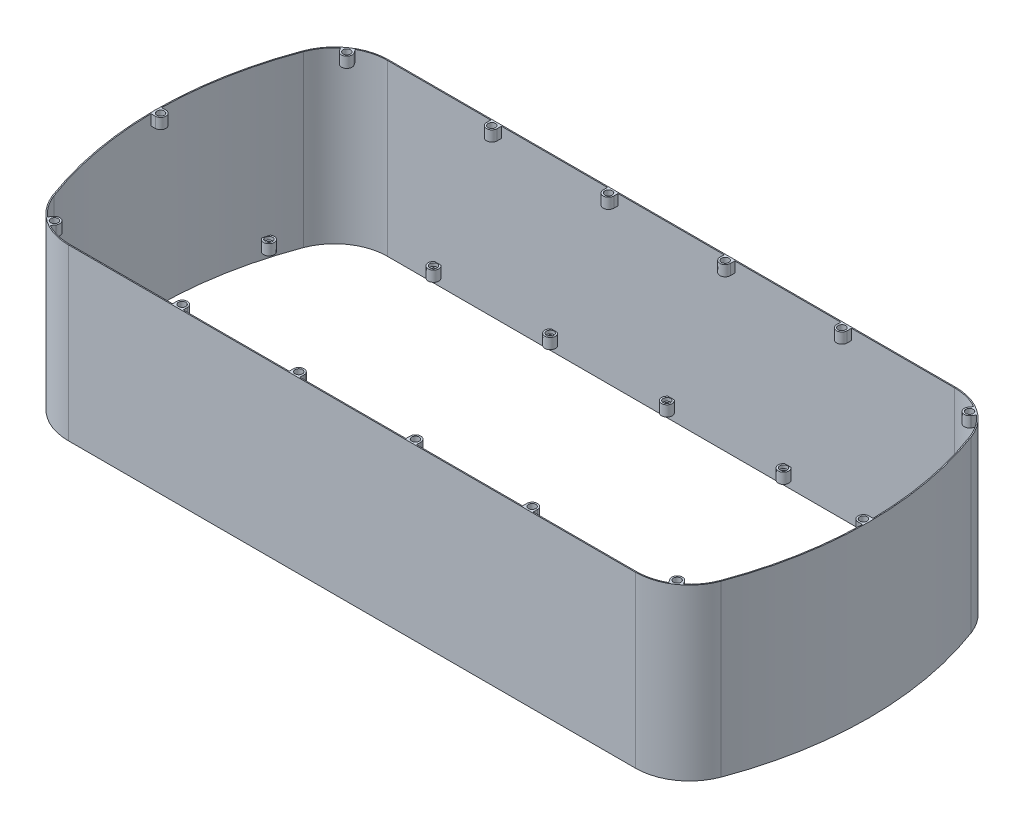
from build123d import *

# Parameters (mm, degrees)
SURFACE_EXTRUDE1_1_DEPTH                     = 160
THICKEN1_T1                                  = 1
BOSS_EXTRUDE1_START                          = -8
SKETCH2_R                                    = 3.4999999999999676
BOSS_EXTRUDE1_DEPTH                          = 10
BOSS_EXTRUDE2_START                          = -13
SKETCH2_3_R                                  = 3.4999999999999676
SKETCH2_3_R_2                                = 1.9999999999999967
BOSS_EXTRUDE2_DEPTH                          = 2
BOSS_EXTRUDE3_START                          = -8
SKETCH2_4_R                                  = 3.5000000000000737
BOSS_EXTRUDE3_DEPTH                          = 10
BOSS_EXTRUDE4_START                          = -13
SKETCH2_5_R                                  = 3.5000000000000737
SKETCH2_5_R_2                                = 2.000000000000103
BOSS_EXTRUDE4_DEPTH                          = 2
LPATTERN1_COUNT                              = 5
LPATTERN1_PITCH                              = 110
MIRROR1_START                                = -8
MIRROR1_AT_THE_SECOND_PLANE_COPY_1_SKETC_R   = 3.5000000000000737
MIRROR1_AT_THE_SECOND_PLANE_COPY_1_DEPTH     = 10
MIRROR1_START_2                              = -13
MIRROR1_AT_THE_SECOND_PLANE_COPY_2_SKETC_R   = 3.5000000000000737
MIRROR1_AT_THE_SECOND_PLANE_COPY_2_SKETC_R_2 = 2.000000000000103
MIRROR1_AT_THE_SECOND_PLANE_COPY_2_DEPTH     = 2
SKETCH3_R                                    = 3.4999999999999676
BOSS_EXTRUDE5_DEPTH                          = 10
BOSS_EXTRUDE6_START                          = -5
SKETCH3_3_R                                  = 3.4999999999999676
SKETCH3_3_R_2                                = 1.9999999999999967
BOSS_EXTRUDE6_DEPTH                          = 5
LPATTERN2_COUNT                              = 4
LPATTERN2_PITCH                              = 110
SKETCH3_5_R                                  = 3.500000000000021
BOSS_EXTRUDE7_DEPTH                          = 10
BOSS_EXTRUDE8_START                          = -5
SKETCH3_6_R                                  = 3.500000000000021
SKETCH3_6_R_2                                = 1.9999999999999967
BOSS_EXTRUDE8_DEPTH                          = 5
MIRROR2_AT_THE_SECOND_PLANE_COPY_1_SKETC_R   = 3.500000000000021
MIRROR2_AT_THE_SECOND_PLANE_COPY_1_DEPTH     = 10
MIRROR2_START                                = -5
MIRROR2_AT_THE_SECOND_PLANE_COPY_2_SKETC_R   = 3.500000000000021
MIRROR2_AT_THE_SECOND_PLANE_COPY_2_SKETC_R_2 = 1.9999999999999967
MIRROR2_AT_THE_SECOND_PLANE_COPY_2_DEPTH     = 5
SKETCH3_7_R                                  = 3.4999999999999623
BOSS_EXTRUDE9_DEPTH                          = 10
BOSS_EXTRUDE10_START                         = -5
SKETCH3_8_R                                  = 3.4999999999999623
SKETCH3_8_R_2                                = 1.9999999999999967
BOSS_EXTRUDE10_DEPTH                         = 5


with BuildPart() as body_1:
    # Surface-Extrude1: a surface, the sketch's curves swept straight by 160 mm
    with BuildLine(Plane(origin=(0, 0, 0), x_dir=(1, 0, 0), z_dir=(0, 1, 0)), mode=Mode.PRIVATE) as surface_extrude1_1_path:
        Line((-267.318125718222, 149.99999999999997), (267.318125718222, 149.99999999999997))
        ThreePointArc((267.318125718222, 149.99999999999997), (295.81433366720404, 141.08486500559997), (314.1486399884393, 117.51864530113492))
        ThreePointArc((314.1486399884393, 117.51864530113492), (335.4101966249685, -4.74e-15), (314.14863998843936, -117.51864530113495))
        ThreePointArc((314.14863998843936, -117.51864530113495), (295.81433366720404, -141.0848650056), (267.318125718222, -150.00000000000003))
        Line((267.318125718222, -150.00000000000003), (-267.31812571822206, -150.00000000000003))
        ThreePointArc((-267.31812571822206, -150.00000000000003), (-295.8143336672041, -141.0848650056), (-314.1486399884393, -117.51864530113491))
        ThreePointArc((-314.1486399884393, -117.51864530113491), (-335.4101966249685, 5.495e-14), (-314.1486399884393, 117.51864530113492))
        ThreePointArc((-314.1486399884393, 117.51864530113492), (-295.81433366720404, 141.08486500559994), (-267.318125718222, 149.99999999999997))
    surface_extrude1_1 = Shell.extrude(surface_extrude1_1_path.wire(), (0 * SURFACE_EXTRUDE1_1_DEPTH, 1 * SURFACE_EXTRUDE1_1_DEPTH, 0 * SURFACE_EXTRUDE1_1_DEPTH))
    add(Solid.thicken(surface_extrude1_1, THICKEN1_T1))

    # Sketch2 → Boss-Extrude1 (add)
    # profile 1 of 2: a face of its own
    with BuildSketch(Plane.XZ.offset(BOSS_EXTRUDE1_START)):
        with BuildLine():
            Line((-216.99999999999997, 149.99999999999997), (-223.00000000000014, 149.99999999999997))
            ThreePointArc((-223.00000000000014, 149.99999999999997), (-220.00000000000006, 140.99999999999991), (-216.99999999999997, 149.99999999999997))
        make_face()
        with Locations(Location((-220.00000000000003, 145.99999999999997, 0), (0, 0, 270))):
            Circle(SKETCH2_R, mode=Mode.SUBTRACT)
    # profile 2 of 2: a face of its own
    with BuildSketch(Plane.XZ.offset(BOSS_EXTRUDE1_START)):
        with BuildLine():
            ThreePointArc((-217.00000000000003, -149.99999999999997), (-220.00000000000009, -141.00000000000003), (-223.00000000000014, -149.99999999999997))
            Line((-223.00000000000014, -150.00000000000003), (-217.00000000000003, -150.00000000000003))
        make_face()
        with Locations(Location((-220.00000000000003, -146, 0), (0, 0, 270))):
            Circle(SKETCH2_R, mode=Mode.SUBTRACT)
    boss_extrude1 = extrude(amount=-BOSS_EXTRUDE1_DEPTH)

    # Sketch2_3 → Boss-Extrude2 (add)
    # profile 1 of 2: a face of its own
    with BuildSketch(Plane.XZ.offset(BOSS_EXTRUDE2_START)):
        with Locations(Location((-220.00000000000003, -146, 0), (0, 0, 270))):
            Circle(SKETCH2_3_R)
        with Locations(Location((-220.00000000000003, -146, 0), (0, 0, 270))):
            Circle(SKETCH2_3_R_2, mode=Mode.SUBTRACT)
    # profile 2 of 2: a face of its own
    with BuildSketch(Plane.XZ.offset(BOSS_EXTRUDE2_START)):
        with Locations(Location((-220.00000000000003, 145.99999999999997, 0), (0, 0, 270))):
            Circle(SKETCH2_3_R)
        with Locations(Location((-220.00000000000003, 145.99999999999997, 0), (0, 0, 270))):
            Circle(SKETCH2_3_R_2, mode=Mode.SUBTRACT)
    boss_extrude2 = extrude(amount=-BOSS_EXTRUDE2_DEPTH)

    # Sketch2_4 → Boss-Extrude3 (add)
    with BuildSketch(Plane.XZ.offset(BOSS_EXTRUDE3_START)):
        with BuildLine():
            ThreePointArc((-323.68703405329086, 87.9016722581764), (-314.33632746614455, 88.64292660929976), (-321.9221066193884, 94.16027437160115))
            ThreePointArc((-321.9221066193882, 94.16027437160109), (-322.81973786485275, 91.0352505618989), (-323.6870340532906, 87.90167225817632))
        make_face()
        with Locations(Location((-319.1486399884395, 89.99999999999997, 0), (0, 0, 270))):
            Circle(SKETCH2_4_R, mode=Mode.SUBTRACT)
    boss_extrude3 = extrude(amount=-BOSS_EXTRUDE3_DEPTH)

    # Sketch2_5 → Boss-Extrude4 (add)
    with BuildSketch(Plane.XZ.offset(BOSS_EXTRUDE4_START)):
        with Locations(Location((-319.1486399884395, 89.99999999999997, 0), (0, 0, 270))):
            Circle(SKETCH2_5_R)
        with Locations(Location((-319.1486399884395, 89.99999999999997, 0), (0, 0, 270))):
            Circle(SKETCH2_5_R_2, mode=Mode.SUBTRACT)
    boss_extrude4 = extrude(amount=-BOSS_EXTRUDE4_DEPTH)

    # LPattern1: Boss-Extrude1, Boss-Extrude2 ×5
    with Locations(*[(i * LPATTERN1_PITCH, 0, 0) for i in range(1, LPATTERN1_COUNT)]):
        add(boss_extrude1)
        add(boss_extrude2)

    # Mirror1: Boss-Extrude3, Boss-Extrude4 across plane
    add(boss_extrude3.mirror(Plane.XY))
    add(boss_extrude4.mirror(Plane.XY))

    # Mirror1 at the second plane: Boss-Extrude3, Boss-Extrude4 across plane
    add(boss_extrude3.mirror(Plane(origin=(0, 0, 0), x_dir=(0, 0, 1), z_dir=(1, 0, 0))))
    add(boss_extrude4.mirror(Plane(origin=(0, 0, 0), x_dir=(0, 0, 1), z_dir=(1, 0, 0))))

    # Mirror1 at the second plane copy 1 sketc → Mirror1 at the second plane copy 1 (add)
    with BuildSketch(Plane(origin=(0, 0, 0), x_dir=(-1, 0, 0), z_dir=(0, -1, 0)).offset(MIRROR1_START)):
        with BuildLine():
            ThreePointArc((-323.68703405329086, 87.9016722581764), (-314.33632746614455, 88.64292660929976), (-321.9221066193884, 94.16027437160115))
            ThreePointArc((-321.9221066193882, 94.16027437160109), (-322.81973786485275, 91.0352505618989), (-323.6870340532906, 87.90167225817632))
        make_face()
        with Locations(Location((-319.1486399884395, 89.99999999999997, 0), (0, 0, 270))):
            Circle(MIRROR1_AT_THE_SECOND_PLANE_COPY_1_SKETC_R, mode=Mode.SUBTRACT)
    extrude(amount=-MIRROR1_AT_THE_SECOND_PLANE_COPY_1_DEPTH)

    # Mirror1 at the second plane copy 2 sketc → Mirror1 at the second plane copy 2 (add)
    with BuildSketch(Plane(origin=(0, 0, 0), x_dir=(-1, 0, 0), z_dir=(0, -1, 0)).offset(MIRROR1_START_2)):
        with Locations(Location((-319.1486399884395, 89.99999999999997, 0), (0, 0, 270))):
            Circle(MIRROR1_AT_THE_SECOND_PLANE_COPY_2_SKETC_R)
        with Locations(Location((-319.1486399884395, 89.99999999999997, 0), (0, 0, 270))):
            Circle(MIRROR1_AT_THE_SECOND_PLANE_COPY_2_SKETC_R_2, mode=Mode.SUBTRACT)
    extrude(amount=-MIRROR1_AT_THE_SECOND_PLANE_COPY_2_DEPTH)

    # Sketch3 → Boss-Extrude5 (add)
    # profile 1 of 6: a face of its own
    with BuildSketch(Plane(origin=(0, 160, 0), x_dir=(1, 0, 0), z_dir=(0, 1, 0))):
        with BuildLine():
            ThreePointArc((-168.00000000000009, 149.99999999999997), (-169.47213595499963, 148.23606797749977), (-170.00000000000003, 145.99999999999997))
            ThreePointArc((-170.00000000000003, 145.99999999999997), (-165.00000000000003, 141.00000000000003), (-160.00000000000003, 146))
            ThreePointArc((-160.00000000000003, 146), (-160.52786404500043, 148.23606797749977), (-161.99999999999997, 149.99999999999997))
            Line((-161.99999999999997, 149.99999999999997), (-168.00000000000009, 149.99999999999997))
        make_face()
        with Locations(Location((-165.00000000000003, 146, 0), (0, 0, 270))):
            Circle(SKETCH3_R, mode=Mode.SUBTRACT)
    # profile 2 of 6: a face of its own
    with BuildSketch(Plane(origin=(0, 160, 0), x_dir=(1, 0, 0), z_dir=(0, 1, 0))):
        with BuildLine():
            ThreePointArc((-161.99999999999997, -149.99999999999997), (-160.52786404500043, -148.23606797749974), (-160, -145.99999999999997))
            ThreePointArc((-160, -145.99999999999997), (-165.00000000000009, -140.99999999999991), (-170.0000000000001, -146))
            ThreePointArc((-170.0000000000001, -146), (-169.4721359549997, -148.23606797749977), (-168.00000000000014, -149.99999999999997))
            Line((-168.00000000000017, -150.00000000000003), (-161.99999999999994, -150.00000000000003))
        make_face()
        with Locations(Location((-165.00000000000003, -145.99999999999997, 0), (0, 0, 270))):
            Circle(SKETCH3_R, mode=Mode.SUBTRACT)
    # profile 3 of 6: a face of its own
    with BuildSketch(Plane(origin=(0, 160, 0), x_dir=(1, 0, 0), z_dir=(0, 1, 0))):
        with BuildLine():
            ThreePointArc((-161.99999999999997, 149.99999999999997), (-160.52786404500043, 148.23606797749977), (-160.00000000000003, 146))
            Line((-160.00000000000003, 146), (-159.99999999999997, 150.00000000000003))
            Line((-159.99999999999997, 149.99999999999997), (-161.99999999999997, 149.99999999999997))
        make_face()
    # profile 4 of 6: a face of its own
    with BuildSketch(Plane(origin=(0, 160, 0), x_dir=(1, 0, 0), z_dir=(0, 1, 0))):
        with BuildLine():
            Line((-170.00000000000003, 149.99999999999997), (-170.00000000000003, 145.99999999999997))
            ThreePointArc((-170.00000000000003, 145.99999999999997), (-169.47213595499963, 148.23606797749977), (-168.00000000000009, 149.99999999999997))
            Line((-168.00000000000009, 149.99999999999997), (-170.00000000000003, 149.99999999999997))
        make_face()
    # profile 5 of 6: a face of its own
    with BuildSketch(Plane(origin=(0, 160, 0), x_dir=(1, 0, 0), z_dir=(0, 1, 0))):
        with BuildLine():
            ThreePointArc((-168.00000000000014, -149.99999999999997), (-169.4721359549997, -148.23606797749977), (-170.0000000000001, -146))
            Line((-170.00000000000009, -146), (-170.00000000000003, -150.00000000000003))
            Line((-170.00000000000006, -150.00000000000003), (-168.00000000000017, -150.00000000000003))
        make_face()
    # profile 6 of 6: a face of its own
    with BuildSketch(Plane(origin=(0, 160, 0), x_dir=(1, 0, 0), z_dir=(0, 1, 0))):
        with BuildLine():
            Line((-160.00000000000003, -150.00000000000003), (-159.99999999999997, -145.99999999999997))
            ThreePointArc((-160, -145.99999999999997), (-160.52786404500043, -148.23606797749974), (-161.99999999999997, -149.99999999999997))
            Line((-161.99999999999994, -150.00000000000003), (-160.00000000000006, -150.00000000000003))
        make_face()
    boss_extrude5 = extrude(amount=-BOSS_EXTRUDE5_DEPTH)

    # Sketch3_3 → Boss-Extrude6 (add)
    # profile 1 of 2: a face of its own
    with BuildSketch(Plane(origin=(0, 160, 0), x_dir=(1, 0, 0), z_dir=(0, 1, 0)).offset(BOSS_EXTRUDE6_START)):
        with Locations(Location((-165.00000000000003, -145.99999999999997, 0), (0, 0, 270))):
            Circle(SKETCH3_3_R)
        with Locations(Location((-165.00000000000003, -145.99999999999997, 0), (0, 0, 270))):
            Circle(SKETCH3_3_R_2, mode=Mode.SUBTRACT)
    # profile 2 of 2: a face of its own
    with BuildSketch(Plane(origin=(0, 160, 0), x_dir=(1, 0, 0), z_dir=(0, 1, 0)).offset(BOSS_EXTRUDE6_START)):
        with Locations(Location((-165.00000000000003, 146, 0), (0, 0, 270))):
            Circle(SKETCH3_3_R)
        with Locations(Location((-165.00000000000003, 146, 0), (0, 0, 270))):
            Circle(SKETCH3_3_R_2, mode=Mode.SUBTRACT)
    boss_extrude6 = extrude(amount=-BOSS_EXTRUDE6_DEPTH)

    # LPattern2: Boss-Extrude5, Boss-Extrude6 ×4
    with Locations(*[(i * LPATTERN2_PITCH, 0, 0) for i in range(1, LPATTERN2_COUNT)]):
        add(boss_extrude5)
        add(boss_extrude6)

    # Sketch3_5 → Boss-Extrude7 (add)
    # profile 1 of 3: a face of its own
    with BuildSketch(Plane(origin=(0, 160, 0), x_dir=(1, 0, 0), z_dir=(0, 1, 0))):
        with BuildLine():
            ThreePointArc((-288.5346370312855, 137.79807580515194), (-288.7627174750273, 139.29098697082793), (-289.4261505307255, 140.64769660005015))
            ThreePointArc((-289.4261505307255, 140.64769660005015), (-291.0645587721248, 142.1453408526987), (-293.1898016412909, 142.78617048687232))
            ThreePointArc((-293.1898016412909, 142.78617048687227), (-295.81433366720404, 141.08486500560002), (-298.3273587924473, 139.2227926612624))
            ThreePointArc((-298.3273587924474, 139.22279266126245), (-298.47177868596225, 137.00773898982828), (-297.6431235318455, 134.94845501025372))
            ThreePointArc((-297.6431235318455, 134.94845501025372), (-292.0417258656095, 133.0261562488937), (-288.5346370312855, 137.79807580515194))
        make_face()
        with Locations(Location((-293.5346370312855, 137.79807580515194, 0), (0, 0, 270))):
            Circle(SKETCH3_5_R, mode=Mode.SUBTRACT)
    # profile 2 of 3: a face of its own
    with BuildSketch(Plane(origin=(0, 160, 0), x_dir=(1, 0, 0), z_dir=(0, 1, 0))):
        with BuildLine():
            ThreePointArc((-293.18980164129096, 142.78617048687232), (-291.0645587721248, 142.1453408526987), (-289.4261505307255, 140.64769660005015))
            Line((-289.4261505307255, 140.64769660005015), (-291.563008132077, 143.72854533069153))
            ThreePointArc((-291.563008132077, 143.72854533069156), (-292.380834519769, 143.26500465189923), (-293.18980164129096, 142.78617048687227))
        make_face()
    # profile 3 of 3: a face of its own
    with BuildSketch(Plane(origin=(0, 160, 0), x_dir=(1, 0, 0), z_dir=(0, 1, 0))):
        with BuildLine():
            Line((-299.77998113319705, 138.02930374089505), (-297.6431235318455, 134.9484550102537))
            ThreePointArc((-297.6431235318455, 134.94845501025372), (-298.47177868596225, 137.0077389898283), (-298.32735879244734, 139.2227926612625))
            ThreePointArc((-298.3273587924472, 139.22279266126242), (-299.0592799576591, 138.63287625259437), (-299.7799811331971, 138.0293037408951))
        make_face()
    boss_extrude7 = extrude(amount=-BOSS_EXTRUDE7_DEPTH)

    # Sketch3_6 → Boss-Extrude8 (add)
    with BuildSketch(Plane(origin=(0, 160, 0), x_dir=(1, 0, 0), z_dir=(0, 1, 0)).offset(BOSS_EXTRUDE8_START)):
        with Locations(Location((-293.5346370312855, 137.79807580515194, 0), (0, 0, 270))):
            Circle(SKETCH3_6_R)
        with Locations(Location((-293.5346370312855, 137.79807580515194, 0), (0, 0, 270))):
            Circle(SKETCH3_6_R_2, mode=Mode.SUBTRACT)
    boss_extrude8 = extrude(amount=-BOSS_EXTRUDE8_DEPTH)

    # Mirror2: Boss-Extrude7, Boss-Extrude8 across plane
    add(boss_extrude7.mirror(Plane(origin=(0, 0, 0), x_dir=(0, 0, 1), z_dir=(1, 0, 0))))
    add(boss_extrude8.mirror(Plane(origin=(0, 0, 0), x_dir=(0, 0, 1), z_dir=(1, 0, 0))))

    # Mirror2 at the second plane: Boss-Extrude7, Boss-Extrude8 across plane
    add(boss_extrude7.mirror(Plane.XY))
    add(boss_extrude8.mirror(Plane.XY))

    # Mirror2 at the second plane copy 1 sketc → Mirror2 at the second plane copy 1 (add)
    # profile 1 of 3: a face of its own
    with BuildSketch(Plane(origin=(0, 160, 0), x_dir=(-1, 0, 0), z_dir=(0, 1, 0))):
        with BuildLine():
            ThreePointArc((-288.5346370312855, 137.79807580515194), (-288.7627174750273, 139.29098697082793), (-289.4261505307255, 140.64769660005015))
            ThreePointArc((-289.4261505307255, 140.64769660005015), (-291.0645587721248, 142.1453408526987), (-293.1898016412909, 142.78617048687232))
            ThreePointArc((-293.1898016412909, 142.78617048687227), (-295.81433366720404, 141.08486500560002), (-298.3273587924473, 139.2227926612624))
            ThreePointArc((-298.3273587924474, 139.22279266126245), (-298.47177868596225, 137.00773898982828), (-297.6431235318455, 134.94845501025372))
            ThreePointArc((-297.6431235318455, 134.94845501025372), (-292.0417258656095, 133.0261562488937), (-288.5346370312855, 137.79807580515194))
        make_face()
        with Locations(Location((-293.5346370312855, 137.79807580515194, 0), (0, 0, 270))):
            Circle(MIRROR2_AT_THE_SECOND_PLANE_COPY_1_SKETC_R, mode=Mode.SUBTRACT)
    # profile 2 of 3: a face of its own
    with BuildSketch(Plane(origin=(0, 160, 0), x_dir=(-1, 0, 0), z_dir=(0, 1, 0))):
        with BuildLine():
            ThreePointArc((-293.18980164129096, 142.78617048687232), (-291.0645587721248, 142.1453408526987), (-289.4261505307255, 140.64769660005015))
            Line((-289.4261505307255, 140.64769660005015), (-291.563008132077, 143.72854533069153))
            ThreePointArc((-291.563008132077, 143.72854533069156), (-292.380834519769, 143.26500465189923), (-293.18980164129096, 142.78617048687227))
        make_face()
    # profile 3 of 3: a face of its own
    with BuildSketch(Plane(origin=(0, 160, 0), x_dir=(-1, 0, 0), z_dir=(0, 1, 0))):
        with BuildLine():
            Line((-299.77998113319705, 138.02930374089505), (-297.6431235318455, 134.9484550102537))
            ThreePointArc((-297.6431235318455, 134.94845501025372), (-298.47177868596225, 137.0077389898283), (-298.32735879244734, 139.2227926612625))
            ThreePointArc((-298.3273587924472, 139.22279266126242), (-299.0592799576591, 138.63287625259437), (-299.7799811331971, 138.0293037408951))
        make_face()
    extrude(amount=-MIRROR2_AT_THE_SECOND_PLANE_COPY_1_DEPTH)

    # Mirror2 at the second plane copy 2 sketc → Mirror2 at the second plane copy 2 (add)
    with BuildSketch(Plane(origin=(0, 160, 0), x_dir=(-1, 0, 0), z_dir=(0, 1, 0)).offset(MIRROR2_START)):
        with Locations(Location((-293.5346370312855, 137.79807580515194, 0), (0, 0, 270))):
            Circle(MIRROR2_AT_THE_SECOND_PLANE_COPY_2_SKETC_R)
        with Locations(Location((-293.5346370312855, 137.79807580515194, 0), (0, 0, 270))):
            Circle(MIRROR2_AT_THE_SECOND_PLANE_COPY_2_SKETC_R_2, mode=Mode.SUBTRACT)
    extrude(amount=-MIRROR2_AT_THE_SECOND_PLANE_COPY_2_DEPTH)

    # Sketch3_7 → Boss-Extrude9 (add)
    # profile 1 of 3: a face of its own
    with BuildSketch(Plane(origin=(0, 160, 0), x_dir=(1, 0, 0), z_dir=(0, 1, 0))):
        with BuildLine():
            ThreePointArc((-326.3181257182219, -8.327e-14), (-327.7825918122892, 3.535533905932689), (-331.31812571822195, 4.999999999999965))
            ThreePointArc((-331.31812571822195, 4.999999999999965), (-333.6144240945209, 4.441510302476664), (-335.39773887657896, 2.890805506802627))
            ThreePointArc((-335.39773887657907, 2.890805506802618), (-335.41019662496853, -1.0303e-13), (-335.39773887657896, -2.890805506802838))
            ThreePointArc((-335.39773887657896, -2.8908055068028284), (-333.6144240945209, -4.441510302476841), (-331.31812571822195, -5.000000000000132))
            ThreePointArc((-331.31812571822195, -5.000000000000132), (-327.7825918122892, -3.535533905932856), (-326.3181257182219, -8.449e-14))
        make_face()
        with Locations(Location((-331.31812571822195, -8.327e-14, 0), (0, 0, 270))):
            Circle(SKETCH3_7_R, mode=Mode.SUBTRACT)
    # profile 2 of 3: a face of its own
    with BuildSketch(Plane(origin=(0, 160, 0), x_dir=(1, 0, 0), z_dir=(0, 1, 0))):
        with BuildLine():
            Line((-335.37292675468007, -5.0000000000001865), (-331.31812571822195, -5.000000000000083))
            ThreePointArc((-331.31812571822195, -5.000000000000132), (-333.6144240945209, -4.441510302476835), (-335.39773887657896, -2.890805506802809))
            ThreePointArc((-335.39773887657896, -2.890805506802824), (-335.3869908675696, -3.945422258376997), (-335.37292675468007, -5.0000000000002025))
        make_face()
    # profile 3 of 3: a face of its own
    with BuildSketch(Plane(origin=(0, 160, 0), x_dir=(1, 0, 0), z_dir=(0, 1, 0))):
        with BuildLine():
            ThreePointArc((-335.39773887657896, 2.890805506802587), (-333.614424094521, 4.441510302476654), (-331.31812571822195, 4.999999999999965))
            Line((-331.31812571822195, 4.999999999999917), (-335.37292675468007, 4.999999999999911))
            ThreePointArc((-335.3729267546802, 4.999999999999897), (-335.38699086756947, 3.94542225837672), (-335.39773887657907, 2.8908055068026037))
        make_face()
    boss_extrude9 = extrude(amount=-BOSS_EXTRUDE9_DEPTH)

    # Sketch3_8 → Boss-Extrude10 (add)
    with BuildSketch(Plane(origin=(0, 160, 0), x_dir=(1, 0, 0), z_dir=(0, 1, 0)).offset(BOSS_EXTRUDE10_START)):
        with Locations(Location((-331.31812571822195, -8.327e-14, 0), (0, 0, 270))):
            Circle(SKETCH3_8_R)
        with Locations(Location((-331.31812571822195, -8.327e-14, 0), (0, 0, 270))):
            Circle(SKETCH3_8_R_2, mode=Mode.SUBTRACT)
    boss_extrude10 = extrude(amount=-BOSS_EXTRUDE10_DEPTH)

    # Mirror3: Boss-Extrude9, Boss-Extrude10 across plane
    add(boss_extrude9.mirror(Plane(origin=(0, 0, 0), x_dir=(0, 0, 1), z_dir=(1, 0, 0))))
    add(boss_extrude10.mirror(Plane(origin=(0, 0, 0), x_dir=(0, 0, 1), z_dir=(1, 0, 0))))


solid = body_1.part
